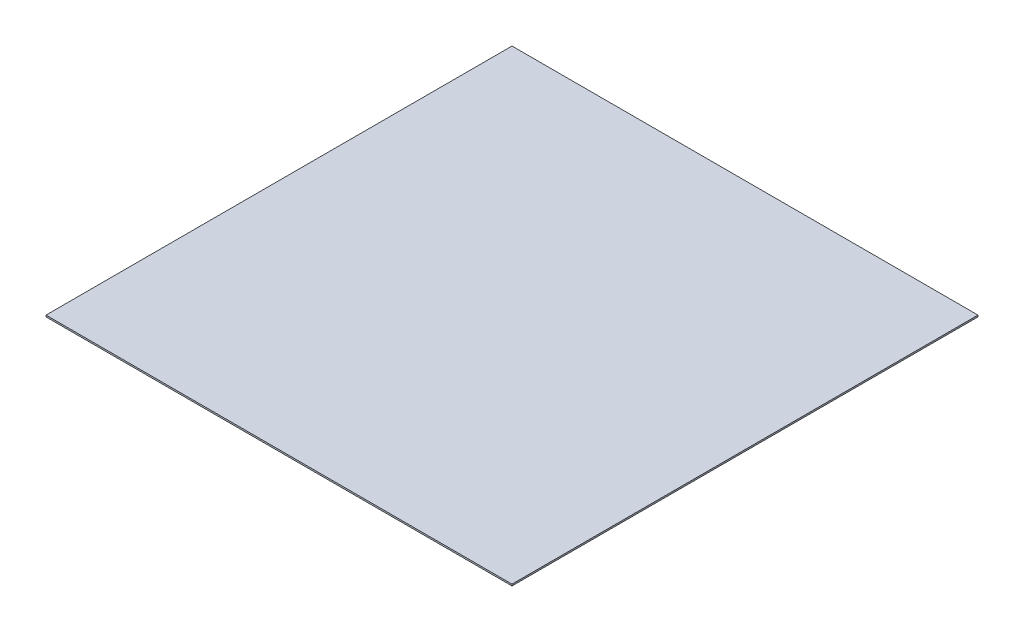
from build123d import *

# Parameters (mm, degrees)
SKETCH1_W           = 870
SKETCH1_H           = 870
BOSS_EXTRUDE1_DEPTH = 3


with BuildPart() as part:
    # Sketch1 → Boss-Extrude1 (new body)
    with BuildSketch(Plane(origin=(0, 0, 0), x_dir=(1, 0, 0), z_dir=(0, 1, 0))):
        Rectangle(SKETCH1_W, SKETCH1_H)
    extrude(amount=BOSS_EXTRUDE1_DEPTH)


solid = part.part
